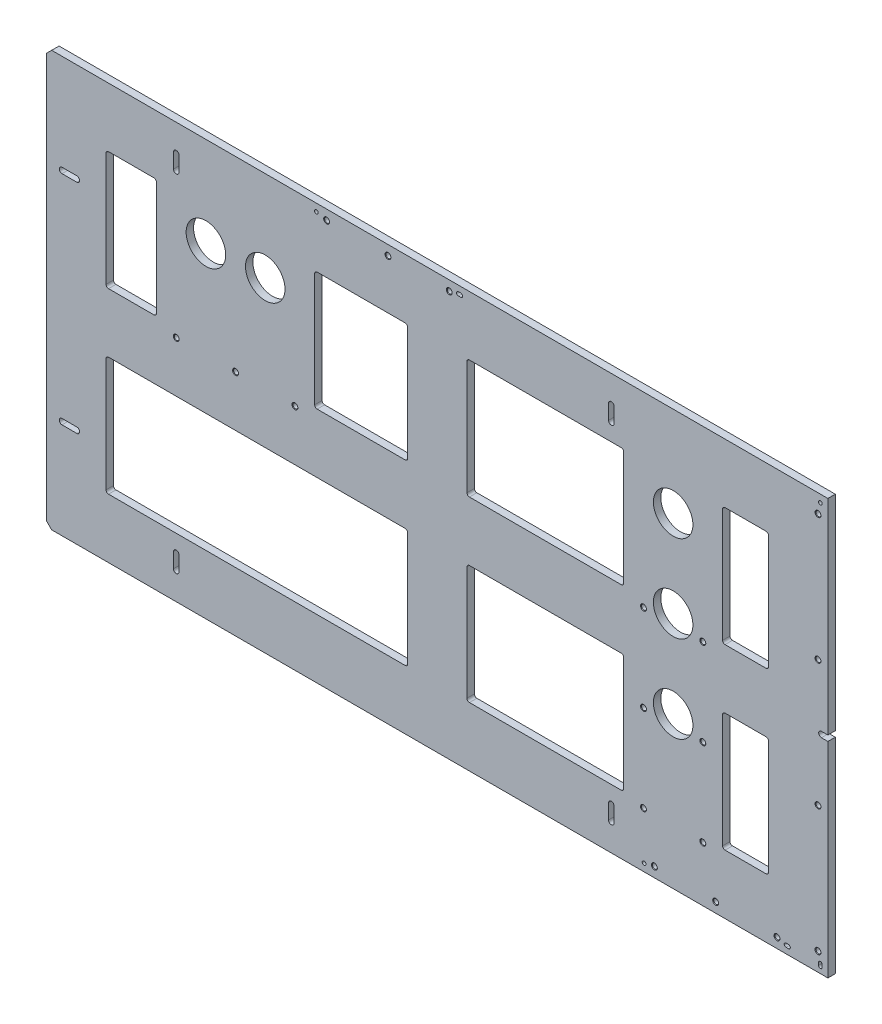
from build123d import *

# Parameters (mm, degrees)
SKETCH6_R                         = 25.4
BOSS_EXTRUDE1_DEPTH               = 4.7625
F_1_4_20_TAPPED_HOLE1_AT_2_COUNT  = 2
F_1_4_20_TAPPED_HOLE1_AT_2_PITCH  = 76.2
F_1_4_20_TAPPED_HOLE1_AT_3_COUNT  = 2
F_1_4_20_TAPPED_HOLE1_AT_3_PITCH  = 76.2
F_1_4_20_TAPPED_HOLE1_AT_4_COUNT  = 2
F_1_4_20_TAPPED_HOLE1_AT_4_PITCH  = 523.9
F_1_4_20_TAPPED_HOLE1_AT_5_COUNT  = 2
F_1_4_20_TAPPED_HOLE1_AT_5_PITCH  = 535.656108317
F_1_4_20_TAPPED_HOLE1_AT_6_COUNT  = 2
F_1_4_20_TAPPED_HOLE1_AT_6_PITCH  = 569.47013575
F_1_4_20_TAPPED_HOLE1_AT_7_COUNT  = 2
F_1_4_20_TAPPED_HOLE1_AT_7_PITCH  = 640.26950225
F_1_4_20_TAPPED_HOLE1_AT_8_COUNT  = 2
F_1_4_20_TAPPED_HOLE1_AT_8_PITCH  = 610.39025744
F_1_4_20_TAPPED_HOLE1_AT_9_COUNT  = 2
F_1_4_20_TAPPED_HOLE1_AT_9_PITCH  = 600.1
F_3_16_0_1875_DIAMETER_HOLE1_D    = 4.7752
CUT_EXTRUDE1_DEPTH                = 10.525
F_1_4_20_TAPPED_HOLE2_AT_2_COUNT  = 2
F_1_4_20_TAPPED_HOLE2_AT_2_PITCH  = 162.052
F_1_4_20_TAPPED_HOLE2_AT_3_COUNT  = 2
F_1_4_20_TAPPED_HOLE2_AT_3_PITCH  = 324.104
F_1_4_20_TAPPED_HOLE2_AT_4_COUNT  = 2
F_1_4_20_TAPPED_HOLE2_AT_4_PITCH  = 486.156
F_1_4_20_TAPPED_HOLE2_AT_5_COUNT  = 2
F_1_4_20_TAPPED_HOLE2_AT_5_PITCH  = 499.861701357
F_1_4_20_TAPPED_HOLE2_AT_6_COUNT  = 2
F_1_4_20_TAPPED_HOLE2_AT_6_PITCH  = 514.157324643
F_1_4_20_TAPPED_HOLE2_AT_7_COUNT  = 2
F_1_4_20_TAPPED_HOLE2_AT_7_PITCH  = 539.679315598
F_1_4_20_TAPPED_HOLE2_AT_8_COUNT  = 2
F_1_4_20_TAPPED_HOLE2_AT_8_PITCH  = 552.405183911
F_1_4_20_TAPPED_HOLE2_AT_9_COUNT  = 2
F_1_4_20_TAPPED_HOLE2_AT_9_PITCH  = 473.683134338
F_1_4_20_TAPPED_HOLE2_AT_10_COUNT = 2
F_1_4_20_TAPPED_HOLE2_AT_10_PITCH = 631.131711981


with BuildPart() as part:
    # Sketch6 → Boss-Extrude1 (new body, symmetric)
    with BuildSketch(Plane.XY):
        with BuildLine():
            Line((-1.27, -385.7625), (-1.27, -122.6312))
            Line((-1.27, -122.6312), (-9.525, -122.6312))
            ThreePointArc((-9.525, -122.6312), (-13.0937, -119.0625), (-9.525, -115.4938))
            Line((-9.525, -115.4938), (-1.27, -115.4938))
            Line((-1.27, -115.4938), (-1.27, 147.6375))
            Line((-1.27, 147.6375), (-998.220000556, 147.6375))
            Line((-998.220000556, 147.6375), (-1004.570000556, 141.2875))
            Line((-1004.570000556, 141.2875), (-1004.570000556, -379.4125))
            Line((-1004.570000556, -379.4125), (-998.220000556, -385.7625))
            Line((-998.220000556, -385.7625), (-1.27, -385.7625))
        make_face()
        with Locations(Location((-723.9, 31.75, 0), (0, 0, 180))):  # turned: the seam where the file's is
            Circle(SKETCH6_R, mode=Mode.SUBTRACT)
        with Locations(Location((-800.1, 31.75, 0), (0, 0, 180))):  # turned: the seam where the file's is
            Circle(SKETCH6_R, mode=Mode.SUBTRACT)
        with Locations(Location((-200, -191.4652, 0), (0, 0, 180))):  # turned: the seam where the file's is
            Circle(SKETCH6_R, mode=Mode.SUBTRACT)
        with Locations(Location((-200, -79.8576, 0), (0, 0, 180))):  # turned: the seam where the file's is
            Circle(SKETCH6_R, mode=Mode.SUBTRACT)
        with Locations(Location((-200, 31.75, 0), (0, 0, 180))):  # turned: the seam where the file's is
            Circle(SKETCH6_R, mode=Mode.SUBTRACT)
        with BuildLine():
            Line((-834.6313, 112.7125), (-834.6313, 93.6625))
            ThreePointArc((-834.6313, 93.6625), (-838.2, 90.0938), (-841.7687, 93.6625))
            Line((-841.7687, 93.6625), (-841.7687, 112.7125))
            ThreePointArc((-841.7687, 112.7125), (-838.2, 116.2812), (-834.6313, 112.7125))
        make_face(mode=Mode.SUBTRACT)
        with BuildLine():
            Line((-275.8313, 112.7125), (-275.8313, 93.6625))
            ThreePointArc((-275.8313, 93.6625), (-279.4, 90.0938), (-282.9687, 93.6625))
            Line((-282.9687, 93.6625), (-282.9687, 112.7125))
            ThreePointArc((-282.9687, 112.7125), (-279.4, 116.2812), (-275.8313, 112.7125))
        make_face(mode=Mode.SUBTRACT)
        with BuildLine():
            Line((-282.9687, -331.7875), (-282.9687, -350.8375))
            ThreePointArc((-282.9687, -350.8375), (-279.4, -354.4062), (-275.8313, -350.8375))
            Line((-275.8313, -350.8375), (-275.8313, -331.7875))
            ThreePointArc((-275.8313, -331.7875), (-279.4, -328.2188), (-282.9687, -331.7875))
        make_face(mode=Mode.SUBTRACT)
        with BuildLine():
            Line((-841.7687, -350.8375), (-841.7687, -331.7875))
            ThreePointArc((-841.7687, -331.7875), (-838.2, -328.2188), (-834.6313, -331.7875))
            Line((-834.6313, -331.7875), (-834.6313, -350.8375))
            ThreePointArc((-834.6313, -350.8375), (-838.2, -354.4062), (-841.7687, -350.8375))
        make_face(mode=Mode.SUBTRACT)
        with BuildLine():
            Line((-984.885, -255.1938), (-965.835, -255.1938))
            ThreePointArc((-965.835, -255.1938), (-962.2663, -258.7625), (-965.835, -262.3312))
            Line((-965.835, -262.3312), (-984.885, -262.3312))
            ThreePointArc((-984.885, -262.3312), (-988.4537, -258.7625), (-984.885, -255.1938))
        make_face(mode=Mode.SUBTRACT)
        with BuildLine():
            Line((-984.885, 24.2062), (-965.835, 24.2062))
            ThreePointArc((-965.835, 24.2062), (-962.2663, 20.6375), (-965.835, 17.0688))
            Line((-965.835, 17.0688), (-984.885, 17.0688))
            ThreePointArc((-984.885, 17.0688), (-988.4537, 20.6375), (-984.885, 24.2062))
        make_face(mode=Mode.SUBTRACT)
        with BuildLine():
            Line((-133.324999722, 71.4375), (-80.645, 71.4375))
            ThreePointArc((-80.645, 71.4375), (-78.39993597, 70.50756403), (-77.47, 68.2625))
            Line((-77.47, 68.2625), (-77.47, -77.7875))
            ThreePointArc((-77.47, -77.7875), (-78.39993597, -80.03256403), (-80.645, -80.9625))
            Line((-80.645, -80.9625), (-133.324999722, -80.9625))
            ThreePointArc((-133.324999722, -80.9625), (-135.570063752, -80.03256403), (-136.499999722, -77.7875))
            Line((-136.499999722, -77.7875), (-136.499999722, 68.2625))
            ThreePointArc((-136.499999722, 68.2625), (-135.570063752, 70.50756403), (-133.324999722, 71.4375))
        make_face(mode=Mode.SUBTRACT)
        with BuildLine():
            Line((-133.324999722, -309.5625), (-80.645, -309.5625))
            ThreePointArc((-80.645, -309.5625), (-78.39993597, -308.63256403), (-77.47, -306.3875))
            Line((-77.47, -306.3875), (-77.47, -160.3375))
            ThreePointArc((-77.47, -160.3375), (-78.39993597, -158.09243597), (-80.645, -157.1625))
            Line((-80.645, -157.1625), (-133.324999722, -157.1625))
            ThreePointArc((-133.324999722, -157.1625), (-135.570063752, -158.09243597), (-136.499999722, -160.3375))
            Line((-136.499999722, -160.3375), (-136.499999722, -306.3875))
            ThreePointArc((-136.499999722, -306.3875), (-135.570063752, -308.63256403), (-133.324999722, -309.5625))
        make_face(mode=Mode.SUBTRACT)
        with BuildLine():
            Line((-263.500000278, 68.2625), (-263.500000278, -77.7875))
            ThreePointArc((-263.500000278, -77.7875), (-264.429936248, -80.03256403), (-266.675000278, -80.9625))
            Line((-266.675000278, -80.9625), (-461.645000278, -80.9625))
            ThreePointArc((-461.645000278, -80.9625), (-463.890064308, -80.03256403), (-464.820000278, -77.7875))
            Line((-464.820000278, -77.7875), (-464.820000278, 68.2625))
            ThreePointArc((-464.820000278, 68.2625), (-463.890064308, 70.50756403), (-461.645000278, 71.4375))
            Line((-461.645000278, 71.4375), (-266.675000278, 71.4375))
            ThreePointArc((-266.675000278, 71.4375), (-264.429936248, 70.50756403), (-263.500000278, 68.2625))
        make_face(mode=Mode.SUBTRACT)
        with BuildLine():
            Line((-263.500000278, -160.3375), (-263.500000278, -306.3875))
            ThreePointArc((-263.500000278, -306.3875), (-264.429936248, -308.63256403), (-266.675000278, -309.5625))
            Line((-266.675000278, -309.5625), (-461.645000278, -309.5625))
            ThreePointArc((-461.645000278, -309.5625), (-463.890064308, -308.63256403), (-464.820000278, -306.3875))
            Line((-464.820000278, -306.3875), (-464.820000278, -160.3375))
            ThreePointArc((-464.820000278, -160.3375), (-463.890064308, -158.09243597), (-461.645000278, -157.1625))
            Line((-461.645000278, -157.1625), (-266.675000278, -157.1625))
            ThreePointArc((-266.675000278, -157.1625), (-264.429936248, -158.09243597), (-263.500000278, -160.3375))
        make_face(mode=Mode.SUBTRACT)
        with BuildLine():
            Line((-660.4, 68.2625), (-660.4, -77.7875))
            ThreePointArc((-660.4, -77.7875), (-659.47006403, -80.03256403), (-657.225, -80.9625))
            Line((-657.225, -80.9625), (-544.195000278, -80.9625))
            ThreePointArc((-544.195000278, -80.9625), (-541.949936248, -80.03256403), (-541.020000278, -77.7875))
            Line((-541.020000278, -77.7875), (-541.020000278, 68.2625))
            ThreePointArc((-541.020000278, 68.2625), (-541.949936248, 70.50756403), (-544.195000278, 71.4375))
            Line((-544.195000278, 71.4375), (-657.225, 71.4375))
            ThreePointArc((-657.225, 71.4375), (-659.47006403, 70.50756403), (-660.4, 68.2625))
        make_face(mode=Mode.SUBTRACT)
        with BuildLine():
            Line((-928.370000556, -160.3375), (-928.370000556, -306.3875))
            ThreePointArc((-928.370000556, -306.3875), (-927.440064587, -308.63256403), (-925.195000556, -309.5625))
            Line((-925.195000556, -309.5625), (-544.195000278, -309.5625))
            ThreePointArc((-544.195000278, -309.5625), (-541.949936248, -308.63256403), (-541.020000278, -306.3875))
            Line((-541.020000278, -306.3875), (-541.020000278, -160.3375))
            ThreePointArc((-541.020000278, -160.3375), (-541.949936248, -158.09243597), (-544.195000278, -157.1625))
            Line((-544.195000278, -157.1625), (-925.195000556, -157.1625))
            ThreePointArc((-925.195000556, -157.1625), (-927.440064587, -158.09243597), (-928.370000556, -160.3375))
        make_face(mode=Mode.SUBTRACT)
        with BuildLine():
            Line((-925.195000556, 71.4375), (-866.775, 71.4375))
            ThreePointArc((-866.775, 71.4375), (-864.52993597, 70.50756403), (-863.6, 68.2625))
            Line((-863.6, 68.2625), (-863.6, -77.7875))
            ThreePointArc((-863.6, -77.7875), (-864.52993597, -80.03256403), (-866.775, -80.9625))
            Line((-866.775, -80.9625), (-925.195000556, -80.9625))
            ThreePointArc((-925.195000556, -80.9625), (-927.440064587, -80.03256403), (-928.370000556, -77.7875))
            Line((-928.370000556, -77.7875), (-928.370000556, 68.2625))
            ThreePointArc((-928.370000556, 68.2625), (-927.440064587, 70.50756403), (-925.195000556, 71.4375))
        make_face(mode=Mode.SUBTRACT)
    extrude(amount=BOSS_EXTRUDE1_DEPTH, both=True)

    # Sketch7 → 1/4-20 Tapped Hole1 (revolve, cut)
    with BuildSketch(Plane(origin=(-762, -92.075, 4.7625), x_dir=(0, -1, 0), z_dir=(1, 0, 0))):
        Polygon((0, 0), (0, 9.525), (3.81, 9.525), (3.175, 8.89), (3.175, 0.635), (3.81, 0), align=None)
    f_1_4_20_tapped_hole1 = revolve(axis=Axis((-762, -92.075, 11.1125), (0, 0, -1)), mode=Mode.SUBTRACT)

    # 1/4-20 Tapped Hole1 at 2: 1/4-20 Tapped Hole1 ×2
    with Locations(*[(i * F_1_4_20_TAPPED_HOLE1_AT_2_PITCH, 0, 0) for i in range(1, F_1_4_20_TAPPED_HOLE1_AT_2_COUNT)]):
        add(f_1_4_20_tapped_hole1, mode=Mode.SUBTRACT)

    # 1/4-20 Tapped Hole1 at 3: 1/4-20 Tapped Hole1 ×2
    with Locations(*[(-i * F_1_4_20_TAPPED_HOLE1_AT_3_PITCH, 0, 0) for i in range(1, F_1_4_20_TAPPED_HOLE1_AT_3_COUNT)]):
        add(f_1_4_20_tapped_hole1, mode=Mode.SUBTRACT)

    # 1/4-20 Tapped Hole1 at 4: 1/4-20 Tapped Hole1 ×2
    with Locations(*[(i * F_1_4_20_TAPPED_HOLE1_AT_4_PITCH, 0, 0) for i in range(1, F_1_4_20_TAPPED_HOLE1_AT_4_COUNT)]):
        add(f_1_4_20_tapped_hole1, mode=Mode.SUBTRACT)

    # 1/4-20 Tapped Hole1 at 5: 1/4-20 Tapped Hole1 ×2
    with Locations(*[Vector(0.978052881, -0.208356814, 0) * (i * F_1_4_20_TAPPED_HOLE1_AT_5_PITCH) for i in range(1, F_1_4_20_TAPPED_HOLE1_AT_5_COUNT)]):
        add(f_1_4_20_tapped_hole1, mode=Mode.SUBTRACT)

    # 1/4-20 Tapped Hole1 at 6: 1/4-20 Tapped Hole1 ×2
    with Locations(*[Vector(0.919978006, -0.391969984, 0) * (i * F_1_4_20_TAPPED_HOLE1_AT_6_PITCH) for i in range(1, F_1_4_20_TAPPED_HOLE1_AT_6_COUNT)]):
        add(f_1_4_20_tapped_hole1, mode=Mode.SUBTRACT)

    # 1/4-20 Tapped Hole1 at 7: 1/4-20 Tapped Hole1 ×2
    with Locations(*[Vector(0.937261572, -0.348626944, 0) * (i * F_1_4_20_TAPPED_HOLE1_AT_7_PITCH) for i in range(1, F_1_4_20_TAPPED_HOLE1_AT_7_COUNT)]):
        add(f_1_4_20_tapped_hole1, mode=Mode.SUBTRACT)

    # 1/4-20 Tapped Hole1 at 8: 1/4-20 Tapped Hole1 ×2
    with Locations(*[Vector(0.983141511, -0.1828463, 0) * (i * F_1_4_20_TAPPED_HOLE1_AT_8_PITCH) for i in range(1, F_1_4_20_TAPPED_HOLE1_AT_8_COUNT)]):
        add(f_1_4_20_tapped_hole1, mode=Mode.SUBTRACT)

    # 1/4-20 Tapped Hole1 at 9: 1/4-20 Tapped Hole1 ×2
    with Locations(*[(i * F_1_4_20_TAPPED_HOLE1_AT_9_PITCH, 0, 0) for i in range(1, F_1_4_20_TAPPED_HOLE1_AT_9_COUNT)]):
        add(f_1_4_20_tapped_hole1, mode=Mode.SUBTRACT)

    # 3/16 (0.1875) Diameter Hole1 (through all)
    with Locations(Plane(origin=(650.0872, -13.92555, 4.7625), x_dir=(1, 0, 0), z_dir=(0, 0, 1))):
        with Locations((-1308.3024, 151.91105), (-661.0092, 151.91105), (-887.4252, -362.18495)):
            Hole(F_3_16_0_1875_DIAMETER_HOLE1_D / 2)

    # Sketch13 → Cut-Extrude1 (cut, through all)
    with BuildSketch(Plane.XY.offset(4.7625)):
        with BuildLine():
            Line((-475.8432, 140.3731), (-472.7952, 140.3731))
            ThreePointArc((-472.7952, 140.3731), (-470.4076, 137.9855), (-472.7952, 135.5979))
            Line((-472.7952, 135.5979), (-475.8432, 135.5979))
            ThreePointArc((-475.8432, 135.5979), (-478.2308, 137.9855), (-475.8432, 140.3731))
        make_face()
        with BuildLine():
            Line((-8.5344, -374.5865), (-8.5344, -377.6345))
            ThreePointArc((-8.5344, -377.6345), (-10.922, -380.0221), (-13.3096, -377.6345))
            Line((-13.3096, -377.6345), (-13.3096, -374.5865))
            ThreePointArc((-13.3096, -374.5865), (-10.922, -372.1989), (-8.5344, -374.5865))
        make_face()
        with BuildLine():
            Line((-54.966, -373.7229), (-51.918, -373.7229))
            ThreePointArc((-51.918, -373.7229), (-49.5304, -376.1105), (-51.918, -378.4981))
            Line((-51.918, -378.4981), (-54.966, -378.4981))
            ThreePointArc((-54.966, -378.4981), (-57.3536, -376.1105), (-54.966, -373.7229))
        make_face()
    extrude(amount=-CUT_EXTRUDE1_DEPTH, mode=Mode.SUBTRACT)

    # Sketch11 → 1/4-20 Tapped Hole2 (revolve, cut)
    with BuildSketch(Plane(origin=(-13.97, 124.0155, 4.7625), x_dir=(0, -1, 0), z_dir=(1, 0, 0))):
        Polygon((0, 0), (0, 9.525), (3.81, 9.525), (3.175, 8.89), (3.175, 0.635), (3.81, 0), align=None)
    f_1_4_20_tapped_hole2 = revolve(axis=Axis((-13.97, 124.0155, 11.1125), (0, 0, -1)), mode=Mode.SUBTRACT)

    # 1/4-20 Tapped Hole2 at 2: 1/4-20 Tapped Hole2 ×2
    with Locations(*[(0, -i * F_1_4_20_TAPPED_HOLE2_AT_2_PITCH, 0) for i in range(1, F_1_4_20_TAPPED_HOLE2_AT_2_COUNT)]):
        add(f_1_4_20_tapped_hole2, mode=Mode.SUBTRACT)

    # 1/4-20 Tapped Hole2 at 3: 1/4-20 Tapped Hole2 ×2
    with Locations(*[(0, -i * F_1_4_20_TAPPED_HOLE2_AT_3_PITCH, 0) for i in range(1, F_1_4_20_TAPPED_HOLE2_AT_3_COUNT)]):
        add(f_1_4_20_tapped_hole2, mode=Mode.SUBTRACT)

    # 1/4-20 Tapped Hole2 at 4: 1/4-20 Tapped Hole2 ×2
    with Locations(*[(0, -i * F_1_4_20_TAPPED_HOLE2_AT_4_PITCH, 0) for i in range(1, F_1_4_20_TAPPED_HOLE2_AT_4_COUNT)]):
        add(f_1_4_20_tapped_hole2, mode=Mode.SUBTRACT)

    # 1/4-20 Tapped Hole2 at 5: 1/4-20 Tapped Hole2 ×2
    with Locations(*[Vector(-0.10538915, -0.994431057, 0) * (i * F_1_4_20_TAPPED_HOLE2_AT_5_PITCH) for i in range(1, F_1_4_20_TAPPED_HOLE2_AT_5_COUNT)]):
        add(f_1_4_20_tapped_hole2, mode=Mode.SUBTRACT)

    # 1/4-20 Tapped Hole2 at 6: 1/4-20 Tapped Hole2 ×2
    with Locations(*[Vector(-0.255602699, -0.966781909, 0) * (i * F_1_4_20_TAPPED_HOLE2_AT_6_PITCH) for i in range(1, F_1_4_20_TAPPED_HOLE2_AT_6_COUNT)]):
        add(f_1_4_20_tapped_hole2, mode=Mode.SUBTRACT)

    # 1/4-20 Tapped Hole2 at 7: 1/4-20 Tapped Hole2 ×2
    with Locations(*[Vector(-0.389416444, -0.921061797, 0) * (i * F_1_4_20_TAPPED_HOLE2_AT_7_PITCH) for i in range(1, F_1_4_20_TAPPED_HOLE2_AT_7_COUNT)]):
        add(f_1_4_20_tapped_hole2, mode=Mode.SUBTRACT)

    # 1/4-20 Tapped Hole2 at 8: 1/4-20 Tapped Hole2 ×2
    with Locations(*[Vector(-0.99980452, 0.019771719, 0) * (i * F_1_4_20_TAPPED_HOLE2_AT_8_PITCH) for i in range(1, F_1_4_20_TAPPED_HOLE2_AT_8_COUNT)]):
        add(f_1_4_20_tapped_hole2, mode=Mode.SUBTRACT)

    # 1/4-20 Tapped Hole2 at 9: 1/4-20 Tapped Hole2 ×2
    with Locations(*[Vector(-0.999734138, 0.023057608, 0) * (i * F_1_4_20_TAPPED_HOLE2_AT_9_PITCH) for i in range(1, F_1_4_20_TAPPED_HOLE2_AT_9_COUNT)]):
        add(f_1_4_20_tapped_hole2, mode=Mode.SUBTRACT)

    # 1/4-20 Tapped Hole2 at 10: 1/4-20 Tapped Hole2 ×2
    with Locations(*[Vector(-0.99985025, 0.017305421, 0) * (i * F_1_4_20_TAPPED_HOLE2_AT_10_PITCH) for i in range(1, F_1_4_20_TAPPED_HOLE2_AT_10_COUNT)]):
        add(f_1_4_20_tapped_hole2, mode=Mode.SUBTRACT)


solid = part.part
